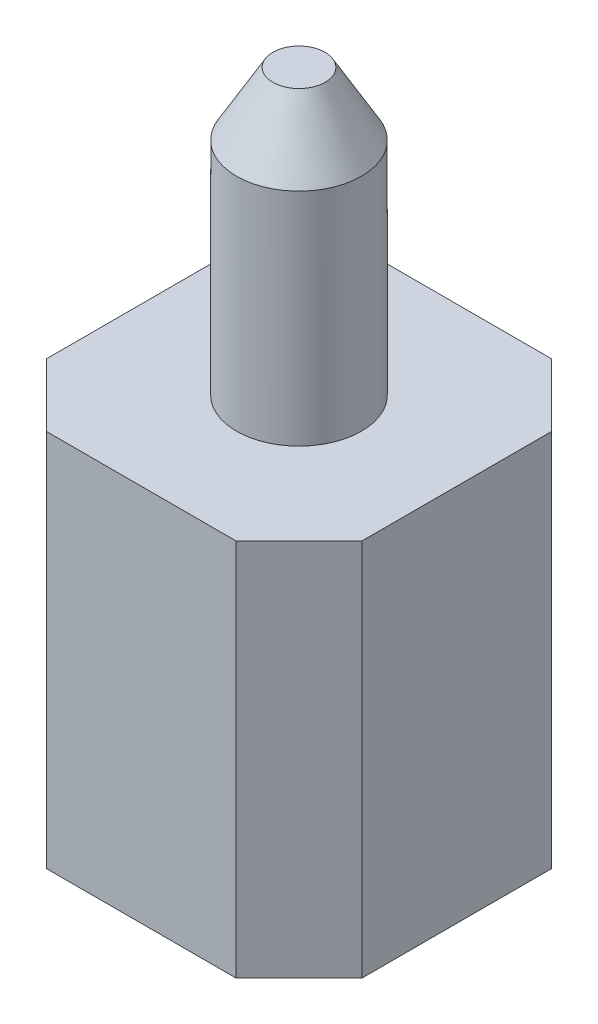
from build123d import *

# Parameters (mm, degrees)
SKETCH1_W           = 2.5
SKETCH1_H           = 2.5
BOSS_EXTRUDE1_DEPTH = 1.5
SKETCH2_R           = 0.4953
BOSS_EXTRUDE2_DEPTH = 2.25
CHAMFER1_SIZE       = 0.5
CHAMFER1_SIZE2      = 0.288675135
CHAMFER2_SIZE       = 0.5


with BuildPart() as part:
    # Sketch1 → Boss-Extrude1 (new body, symmetric)
    with BuildSketch(Plane(origin=(0, 0, 0), x_dir=(1, 0, 0), z_dir=(0, 1, 0))):
        Rectangle(SKETCH1_W, SKETCH1_H)
    extrude(amount=BOSS_EXTRUDE1_DEPTH, both=True)

    # Sketch2 → Boss-Extrude2 (add)
    with BuildSketch(Plane(origin=(0, 1.5, 0), x_dir=(1, 0, 0), z_dir=(0, 1, 0))):
        Circle(SKETCH2_R)
    extrude(amount=BOSS_EXTRUDE2_DEPTH)

    # Chamfer1
    chamfer1_edges = [part.edges().sort_by_distance(p)[0] for p in [
        (-0.4953, 3.75, 0),
    ]]
    chamfer1_side = [part.faces().sort_by_distance(p)[0] for p in [
        (-0.4953, 2.625, 0),
    ]]
    chamfer(chamfer1_edges, length=CHAMFER1_SIZE, length2=CHAMFER1_SIZE2, reference=chamfer1_side[0])

    # Chamfer2
    chamfer2_edges = [part.edges().sort_by_distance(p)[0] for p in [
        (-1.25, 0, 1.25),
        (-1.25, 0, -1.25),
        (1.25, 0, -1.25),
        (1.25, 0, 1.25),
    ]]
    chamfer(chamfer2_edges, length=CHAMFER2_SIZE)


solid = part.part
